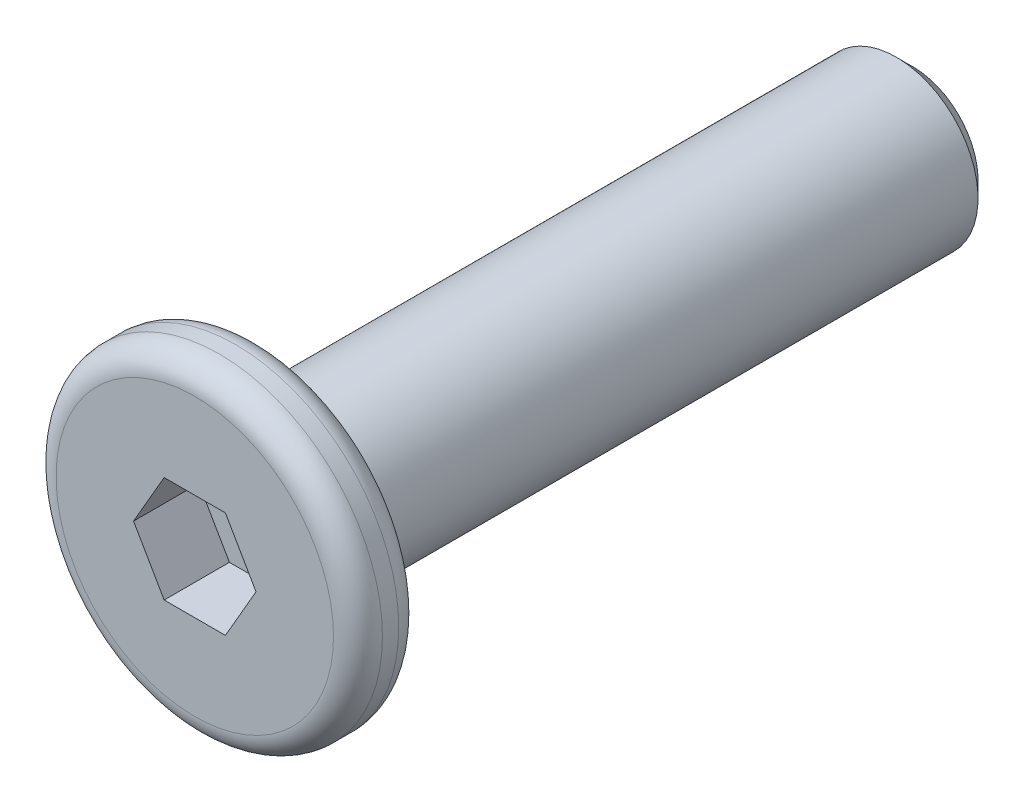
from build123d import *

# Parameters (mm, degrees)
SKETCH_1_R          = 2
EXTRUDE_1_DEPTH     = 0.4
SKETCH_2_R          = 1
EXTRUDE_2_DEPTH     = 8
CHAMFER_1_SIZE      = 0.2
CUT_EXTRUDE_1_DEPTH = 0.8
FILLET_2_R          = 0.3


with BuildPart() as part:
    # 草图1 → 凸台-拉伸1 (new body, symmetric)
    with BuildSketch(Plane.XY):
        Circle(SKETCH_1_R)
    extrude(amount=EXTRUDE_1_DEPTH, both=True)

    # 草图2 → 凸台-拉伸2 (add)
    with BuildSketch(Plane(origin=(0, 0, -0.4), x_dir=(-1, 0, 0), z_dir=(0, 0, -1))):
        Circle(SKETCH_2_R)
    extrude(amount=EXTRUDE_2_DEPTH)

    # 倒角1
    chamfer_1_edges = [part.edges().sort_by_distance(p)[0] for p in [
        (1, 0, -8.4),
    ]]
    chamfer(chamfer_1_edges, length=CHAMFER_1_SIZE)

    # 草图3 → 切除-拉伸1 (cut)
    with BuildSketch(Plane.XY.offset(0.4)):
        Polygon((0.75055535, 0), (0.375277675, 0.65), (-0.375277675, 0.65), (-0.75055535, 0), (-0.375277675, -0.65), (0.375277675, -0.65), align=None)
    extrude(amount=-CUT_EXTRUDE_1_DEPTH, mode=Mode.SUBTRACT)

    # 圆角2
    fillet_2_edges = [part.edges().sort_by_distance(p)[0] for p in [
        (-2, 0, -0.4),
        (-2, 0, 0.4),
    ]]
    fillet(fillet_2_edges, radius=FILLET_2_R)


solid = part.part
